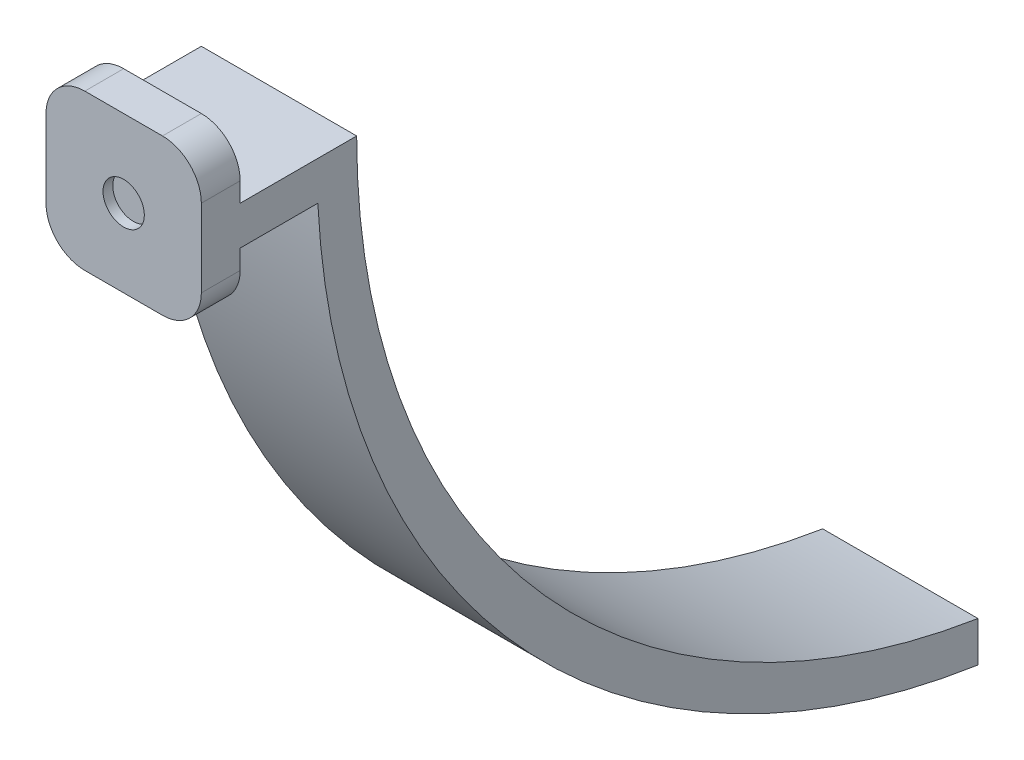
from build123d import *

# Parameters (mm, degrees)
BOSS_EXTRUDE1_DEPTH = 12.7
SKETCH2_R           = 3.3782
CUT_EXTRUDE1_DEPTH  = 1.5875
FILLET2_R           = 6.35


with BuildPart() as part:
    # Sketch1 → Boss-Extrude1 (new body, symmetric)
    with BuildSketch(Plane(origin=(0, 0, 0), x_dir=(0, 0, -1), z_dir=(1, 0, 0))):
        with BuildLine():
            Line((0, 0), (0, 25.4))
            Line((0, 25.4), (6.35, 25.4))
            Line((6.35, 25.4), (6.35, 15.875))
            Line((6.35, 15.875), (25.4, 15.875))
            ThreePointArc((25.4, 15.875), (54.249114928, -62.413057838), (127, -103.2615603))
            Line((127, -103.2615603), (127, -109.848585695))
            ThreePointArc((127, -109.848585695), (51.735823624, -69.413678232), (19.05, 9.525))
            Line((19.05, 9.525), (6.35, 9.525))
            Line((6.35, 9.525), (6.35, 0))
            Line((6.35, 0), (0, 0))
        make_face()
    extrude(amount=BOSS_EXTRUDE1_DEPTH, both=True)

    # Sketch2 → Cut-Extrude1 (cut)
    with BuildSketch(Plane.XY):
        with Locations((0, 12.7)):
            Circle(SKETCH2_R)
    extrude(amount=-CUT_EXTRUDE1_DEPTH, mode=Mode.SUBTRACT)

    # Fillet2
    fillet2_edges = [part.edges().sort_by_distance(p)[0] for p in [
        (-12.7, 25.4, -3.175),
        (-12.7, 0, -3.175),
        (12.7, 25.4, -3.175),
        (12.7, 0, -3.175),
    ]]
    fillet(fillet2_edges, radius=FILLET2_R)


solid = part.part
